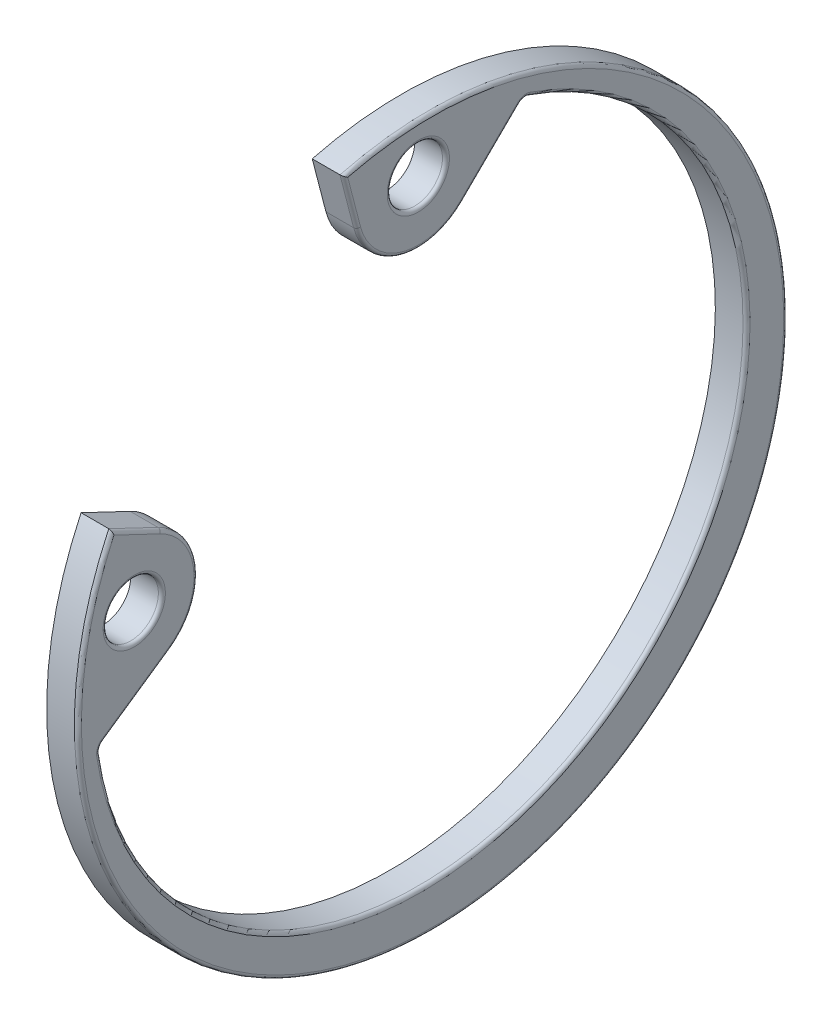
from build123d import *

# Parameters (mm, degrees)
SKETCH1_R           = 0.7874
BOSS_EXTRUDE1_DEPTH = 0.89
FILLET1_R           = 0.1


with BuildPart() as part:
    # Sketch1 → Boss-Extrude1 (new body)
    with BuildSketch(Plane(origin=(0, 0, 0), x_dir=(0, 0, -1), z_dir=(1, 0, 0))):
        with BuildLine():
            Line((-9.372828774, -0.73517355), (-7.483771729, 0.565616411))
            ThreePointArc((-7.483771729, 0.565616411), (-6.708837054, 2.194029076), (-7.731616452, 3.679348524))
            Line((-7.731616452, 3.679348524), (-9.134018919, 4.346728677))
            ThreePointArc((-9.134018919, 4.346728677), (6.441225552, -7.799677249), (-2.541446831, 9.791087775))
            Line((-2.541446831, 9.791087775), (-2.151242771, 8.287801467))
            ThreePointArc((-2.151242771, 8.287801467), (-0.886078684, 7.002651136), (0.859476194, 7.45574021))
            Line((0.859476194, 7.45574021), (2.493954423, 9.06479955))
            ThreePointArc((2.493954423, 9.06479955), (2.616717918, 9.131670791), (2.756271382, 9.123456835))
            ThreePointArc((2.756271382, 9.123456835), (5.588056342, -6.766575002), (-9.480022186, -0.981669875))
            ThreePointArc((-9.480022186, -0.981669875), (-9.461703842, -0.843080275), (-9.372828774, -0.73517355))
        make_face()
        with Locations((-8.506551123, 2.050935853)):
            Circle(SKETCH1_R, mode=Mode.SUBTRACT)
        with Locations((-0.405687887, 8.740890535)):
            Circle(SKETCH1_R, mode=Mode.SUBTRACT)
    extrude(amount=BOSS_EXTRUDE1_DEPTH)

    # Fillet1
    fillet1_edges = [part.edges().sort_by_distance(p)[0] for p in [
        (0.89, 2.194029076, 6.708837054),
        (0.89, 4.0130386, 8.432817685),
        (0.89, -7.799677249, -6.441225552),
        (0.89, 9.039444621, 2.346344801),
        (0.89, 2.050935853, 9.293951123),
        (0.89, 7.002651136, 0.886078684),
        (0.89, 8.740890535, 1.193087887),
        (0.89, 8.26026988, -1.676715309),
        (0.89, 9.131670791, -2.616717918),
        (0.89, -6.766575002, -5.588056342),
        (0.89, -0.843080275, 9.461703842),
        (0.89, -0.08477857, 8.428300251),
    ]]
    fillet(fillet1_edges, radius=FILLET1_R)


solid = part.part
